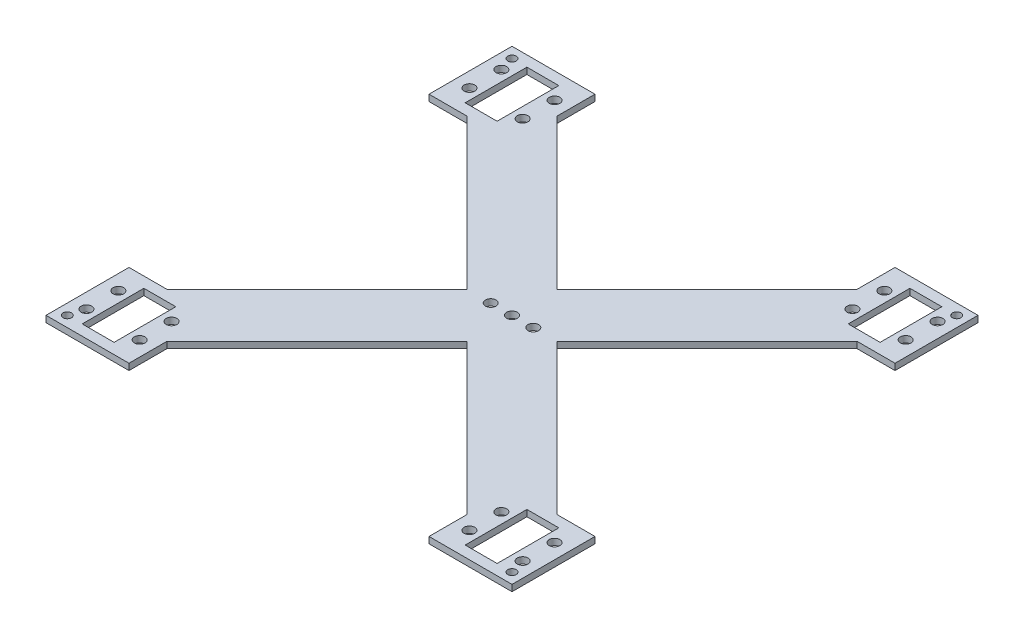
from build123d import *

# Parameters (mm, degrees)
SKETCH1_R           = 2
SKETCH1_R_2         = 2.5
SKETCH1_W           = 15
SKETCH1_H           = 29
BOSS_EXTRUDE1_DEPTH = 3


with BuildPart() as part:
    # Sketch1 → Boss-Extrude1 (new body)
    with BuildSketch(Plane(origin=(0, 0, 0), x_dir=(1, 0, 0), z_dir=(0, 1, 0))):
        Polygon((-70.5, -91.713203436), (0, -21.213203436), (70.5, -91.713203436), (70.5, -109.5), (109.5, -109.5), (109.5, -70.5), (91.713203436, -70.5), (21.213203436, 0), (91.713203436, 70.5), (109.5, 70.5), (109.5, 109.5), (70.5, 109.5), (70.5, 91.713203436), (0, 21.213203436), (-70.5, 91.713203436), (-70.5, 109.5), (-109.5, 109.5), (-109.5, 70.5), (-91.713203436, 70.5), (-21.213203436, 0), (-91.713203436, -70.5), (-109.5, -70.5), (-109.5, -109.5), (-70.5, -109.5), align=None)
        with Locations((-104.5, -104.5)):
            Circle(SKETCH1_R, mode=Mode.SUBTRACT)
        with Locations((-102.5, -82.5)):
            Circle(SKETCH1_R_2, mode=Mode.SUBTRACT)
        with Locations((-77.5, -82.5)):
            Circle(SKETCH1_R_2, mode=Mode.SUBTRACT)
        with Locations((-77.5, -97.5)):
            Circle(SKETCH1_R_2, mode=Mode.SUBTRACT)
        with Locations((-102.5, -97.5)):
            Circle(SKETCH1_R_2, mode=Mode.SUBTRACT)
        with Locations((102.5, -97.5)):
            Circle(SKETCH1_R_2, mode=Mode.SUBTRACT)
        with Locations((77.5, -97.5)):
            Circle(SKETCH1_R_2, mode=Mode.SUBTRACT)
        with Locations((77.5, -82.5)):
            Circle(SKETCH1_R_2, mode=Mode.SUBTRACT)
        with Locations((102.5, -82.5)):
            Circle(SKETCH1_R_2, mode=Mode.SUBTRACT)
        with Locations((104.5, -104.5)):
            Circle(SKETCH1_R, mode=Mode.SUBTRACT)
        with Locations((104.5, 104.5)):
            Circle(SKETCH1_R, mode=Mode.SUBTRACT)
        with Locations((102.5, 82.5)):
            Circle(SKETCH1_R_2, mode=Mode.SUBTRACT)
        with Locations((77.5, 82.5)):
            Circle(SKETCH1_R_2, mode=Mode.SUBTRACT)
        with Locations((77.5, 97.5)):
            Circle(SKETCH1_R_2, mode=Mode.SUBTRACT)
        with Locations((102.5, 97.5)):
            Circle(SKETCH1_R_2, mode=Mode.SUBTRACT)
        with Locations((-102.5, 97.5)):
            Circle(SKETCH1_R_2, mode=Mode.SUBTRACT)
        with Locations((-77.5, 97.5)):
            Circle(SKETCH1_R_2, mode=Mode.SUBTRACT)
        with Locations((-77.5, 82.5)):
            Circle(SKETCH1_R_2, mode=Mode.SUBTRACT)
        with Locations((-102.5, 82.5)):
            Circle(SKETCH1_R_2, mode=Mode.SUBTRACT)
        with Locations((-104.5, 104.5)):
            Circle(SKETCH1_R, mode=Mode.SUBTRACT)
        Circle(SKETCH1_R_2, mode=Mode.SUBTRACT)
        with Locations((-10, 0)):
            Circle(SKETCH1_R_2, mode=Mode.SUBTRACT)
        with Locations((10, 0)):
            Circle(SKETCH1_R_2, mode=Mode.SUBTRACT)
        with Locations((-90, -90)):
            Rectangle(SKETCH1_W, SKETCH1_H, mode=Mode.SUBTRACT)
        with Locations((90, -90)):
            Rectangle(SKETCH1_W, SKETCH1_H, mode=Mode.SUBTRACT)
        with Locations((90, 90)):
            Rectangle(SKETCH1_W, SKETCH1_H, mode=Mode.SUBTRACT)
        with Locations((-90, 90)):
            Rectangle(SKETCH1_W, SKETCH1_H, mode=Mode.SUBTRACT)
    extrude(amount=BOSS_EXTRUDE1_DEPTH)


solid = part.part
